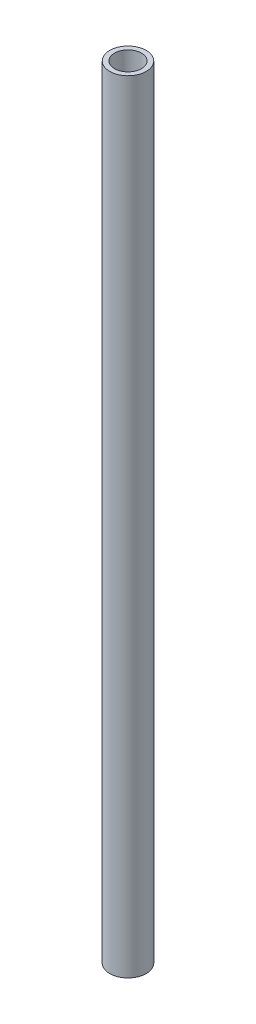
from build123d import *

# Parameters (mm, degrees)
SKETCH1_R           = 10.668
SKETCH1_R_2         = 7.8994
BOSS_EXTRUDE1_DEPTH = 457.2


with BuildPart() as part:
    # Sketch1 → Boss-Extrude1 (new body)
    with BuildSketch(Plane(origin=(0, 0, 0), x_dir=(1, 0, 0), z_dir=(0, 1, 0))):
        Circle(SKETCH1_R)
        Circle(SKETCH1_R_2, mode=Mode.SUBTRACT)
    extrude(amount=BOSS_EXTRUDE1_DEPTH)


solid = part.part
